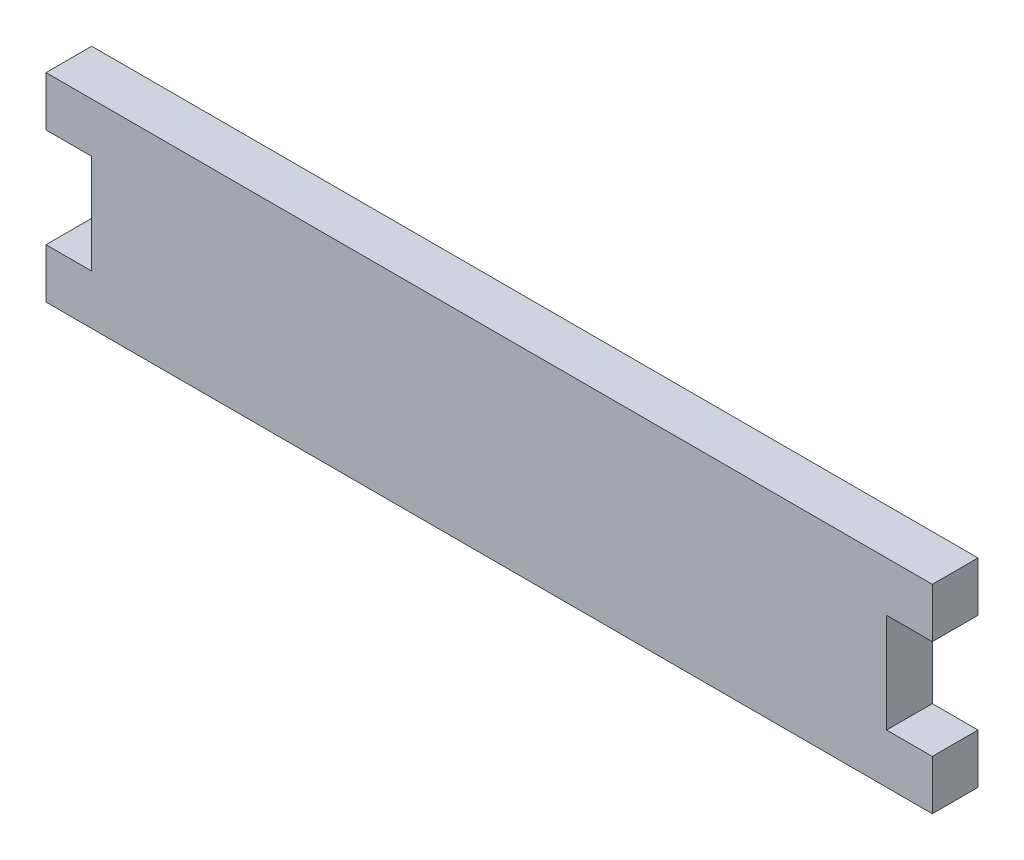
from build123d import *

# Parameters (mm, degrees)
BOSS_EXTRUDE1_DEPTH = 5.842


with BuildPart() as part:
    # Sketch1 → Boss-Extrude1 (new body)
    with BuildSketch(Plane.XY):
        Polygon((56.642, 6.35), (50.8, 6.35), (50.8, -6.35), (56.642, -6.35), (56.642, -12.7), (50.8, -12.7), (-50.8, -12.7), (-56.642, -12.7), (-56.642, -6.35), (-50.8, -6.35), (-50.8, 6.35), (-56.642, 6.35), (-56.642, 12.7), (-50.8, 12.7), (50.8, 12.7), (56.642, 12.7), align=None)
    extrude(amount=BOSS_EXTRUDE1_DEPTH)


solid = part.part
